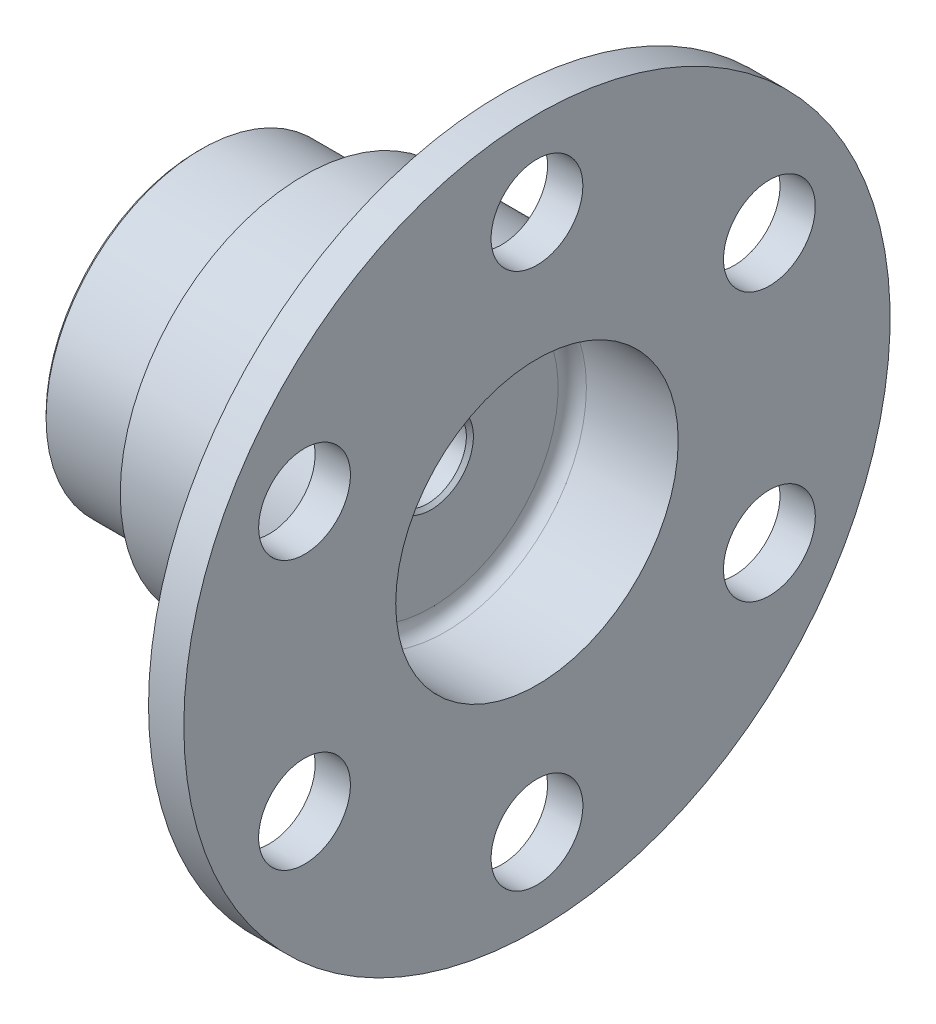
from build123d import *

# Parameters (mm, degrees)
SZKIC4_R                    = 6.5
WYTNIJ_WYCI_GNI_CIE1_DEPTH  = 10
SZYK_KO_OWY1_COUNT          = 6
ZAOKR_GLENIE1_R             = 2
SZKIC6_R                    = 16.5
DODANIE_WYCI_GNI_CIE1_DEPTH = 26
SFAZOWANIE1_SIZE            = 0.5


with BuildPart() as part:
    # Szkic2 → Obrót1 (revolve)
    with BuildSketch(Plane.XY):
        Polygon((0, 15.75), (29, 15.75), (29, 5.5), (33, 5.5), (33, 20), (48, 20), (48, 50), (43, 50), (43, 26), (15, 26), (15, 22), (0, 22), align=None)
    revolve(axis=Axis((0, 0, 0), (1, 0, 0)))

    # Szkic4 → Wytnij-wyciągnięcie1 (cut)
    with BuildSketch(Plane(origin=(48, 0, 0), x_dir=(0, 0, -1), z_dir=(1, 0, 0))):
        with Locations((0, 38)):
            Circle(SZKIC4_R)
    wytnij_wyci_gni_cie1 = extrude(amount=-WYTNIJ_WYCI_GNI_CIE1_DEPTH, mode=Mode.SUBTRACT)

    # Szyk kołowy1: Wytnij-wyciągnięcie1 ×6 about axis
    szyk_ko_owy1_axis = Axis((0, 0, 0), (1, 0, 0))
    for i in range(1, SZYK_KO_OWY1_COUNT):
        add(wytnij_wyci_gni_cie1.rotate(szyk_ko_owy1_axis, i * 360 / SZYK_KO_OWY1_COUNT), mode=Mode.SUBTRACT)

    # Zaokrąglenie1
    zaokr_glenie1_edges = [part.edges().sort_by_distance(p)[0] for p in [
        (33, -20, 0),
        (43, -26, 0),
    ]]
    fillet(zaokr_glenie1_edges, radius=ZAOKR_GLENIE1_R)

    # Szkic6 → Dodanie-wyciągnięcie1 (add)
    with BuildSketch(Plane.ZY.offset(-29)):
        Circle(SZKIC6_R)
        with BuildLine():
            Line((-4.32821665, -14.980955932), (-4.33920313, -15.180955932))
            ThreePointArc((-4.33920313, -15.180955932), (-4.301860669, -15.308717905), (-4.192604113, -15.384748071))
            ThreePointArc((-4.192604113, -15.384748071), (-0.874869369, -15.926290292), (2.482220063, -15.751412191))
            ThreePointArc((2.482220063, -15.751412191), (2.599147134, -15.687806835), (2.650259222, -15.564903882))
            Line((2.650259222, -15.564903882), (2.661245702, -15.364903882))
            Line((2.661245702, -15.364903882), (2.775629759, -13.282634507))
            ThreePointArc((2.775629759, -13.282634507), (2.845574347, -13.106003698), (3.007591812, -13.006801739))
            ThreePointArc((3.007591812, -13.006801739), (6.030810048, -11.910156597), (8.704052682, -10.122349871))
            ThreePointArc((8.704052682, -10.122349871), (8.879904359, -10.050468889), (9.063673937, -10.098629351))
            Line((9.063673937, -10.098629351), (10.809780085, -11.238823538))
            Line((10.809780085, -11.238823538), (10.977491925, -11.348338109))
            ThreePointArc((10.977491925, -11.348338109), (11.106808271, -11.379879576), (11.227280604, -11.323275705))
            ThreePointArc((11.227280604, -11.323275705), (13.355137297, -8.720804245), (14.882233134, -5.726040463))
            ThreePointArc((14.882233134, -5.726040463), (14.885612816, -5.592975971), (14.80473178, -5.487260129))
            Line((14.80473178, -5.487260129), (14.63701994, -5.377745558))
            Line((14.63701994, -5.377745558), (12.890913792, -4.237551371))
            ThreePointArc((12.890913792, -4.237551371), (12.772919318, -4.088662177), (12.768016635, -3.898749956))
            ThreePointArc((12.768016635, -3.898749956), (13.3299032, -0.732243591), (13.118238475, 2.476755803))
            ThreePointArc((13.118238475, 2.476755803), (13.143913557, 2.664988314), (13.27750653, 2.800057205))
            Line((13.27750653, 2.800057205), (15.137996735, 3.742132394))
            Line((15.137996735, 3.742132394), (15.316695056, 3.832617823))
            ThreePointArc((15.316695056, 3.832617823), (15.40866894, 3.928838329), (15.419884717, 4.061472366))
            ThreePointArc((15.419884717, 4.061472366), (14.230006666, 7.205486047), (12.400013071, 10.025371728))
            ThreePointArc((12.400013071, 10.025371728), (12.286465682, 10.094830864), (12.154472559, 10.077643754))
            Line((12.154472559, 10.077643754), (11.975774238, 9.987158325))
            Line((11.975774238, 9.987158325), (10.115284033, 9.045083136))
            ThreePointArc((10.115284033, 9.045083136), (9.927344971, 9.017341522), (9.760424822, 9.108051784))
            ThreePointArc((9.760424822, 9.108051784), (7.299093152, 11.177913005), (4.414185793, 12.599105674))
            ThreePointArc((4.414185793, 12.599105674), (4.264009198, 12.715457202), (4.213832593, 12.898686556))
            Line((4.213832593, 12.898686556), (4.32821665, 14.980955932))
            Line((4.32821665, 14.980955932), (4.33920313, 15.180955932))
            ThreePointArc((4.33920313, 15.180955932), (4.301860669, 15.308717905), (4.192604113, 15.384748071))
            ThreePointArc((4.192604113, 15.384748071), (0.874869369, 15.926290292), (-2.482220063, 15.751412191))
            ThreePointArc((-2.482220063, 15.751412191), (-2.599147134, 15.687806835), (-2.650259222, 15.564903882))
            Line((-2.650259222, 15.564903882), (-2.661245702, 15.364903882))
            Line((-2.661245702, 15.364903882), (-2.775629759, 13.282634507))
            ThreePointArc((-2.775629759, 13.282634507), (-2.845574347, 13.106003698), (-3.007591812, 13.006801739))
            ThreePointArc((-3.007591812, 13.006801739), (-6.030810048, 11.910156597), (-8.704052682, 10.122349871))
            ThreePointArc((-8.704052682, 10.122349871), (-8.879904359, 10.050468889), (-9.063673937, 10.098629351))
            Line((-9.063673937, 10.098629351), (-10.809780085, 11.238823538))
            Line((-10.809780085, 11.238823538), (-10.977491925, 11.348338109))
            ThreePointArc((-10.977491925, 11.348338109), (-11.106808271, 11.379879576), (-11.227280604, 11.323275705))
            ThreePointArc((-11.227280604, 11.323275705), (-13.355137297, 8.720804245), (-14.882233134, 5.726040463))
            ThreePointArc((-14.882233134, 5.726040463), (-14.885612816, 5.592975971), (-14.80473178, 5.487260129))
            Line((-14.80473178, 5.487260129), (-14.63701994, 5.377745558))
            Line((-14.63701994, 5.377745558), (-12.890913792, 4.237551371))
            ThreePointArc((-12.890913792, 4.237551371), (-12.772919318, 4.088662177), (-12.768016635, 3.898749956))
            ThreePointArc((-12.768016635, 3.898749956), (-13.3299032, 0.732243591), (-13.118238475, -2.476755803))
            ThreePointArc((-13.118238475, -2.476755803), (-13.143913557, -2.664988314), (-13.27750653, -2.800057205))
            Line((-13.27750653, -2.800057205), (-15.137996735, -3.742132394))
            Line((-15.137996735, -3.742132394), (-15.316695056, -3.832617823))
            ThreePointArc((-15.316695056, -3.832617823), (-15.40866894, -3.928838329), (-15.419884717, -4.061472366))
            ThreePointArc((-15.419884717, -4.061472366), (-14.230006666, -7.205486047), (-12.400013071, -10.025371728))
            ThreePointArc((-12.400013071, -10.025371728), (-12.286465682, -10.094830864), (-12.154472559, -10.077643754))
            Line((-12.154472559, -10.077643754), (-11.975774238, -9.987158325))
            Line((-11.975774238, -9.987158325), (-10.115284033, -9.045083136))
            ThreePointArc((-10.115284033, -9.045083136), (-9.927344971, -9.017341522), (-9.760424822, -9.108051784))
            ThreePointArc((-9.760424822, -9.108051784), (-7.299093152, -11.177913005), (-4.414185793, -12.599105674))
            ThreePointArc((-4.414185793, -12.599105674), (-4.264009198, -12.715457202), (-4.213832593, -12.898686556))
            Line((-4.213832593, -12.898686556), (-4.32821665, -14.980955932))
        make_face(mode=Mode.SUBTRACT)
    extrude(amount=DODANIE_WYCI_GNI_CIE1_DEPTH)

    # Sfazowanie1
    sfazowanie1_edges = [part.edges().sort_by_distance(p)[0] for p in [
        (33, -5.5, 0),
        (29, -5.5, 0),
        (0, -15.75, 0),
        (0, -22, 0),
    ]]
    chamfer(sfazowanie1_edges, length=SFAZOWANIE1_SIZE)


solid = part.part
